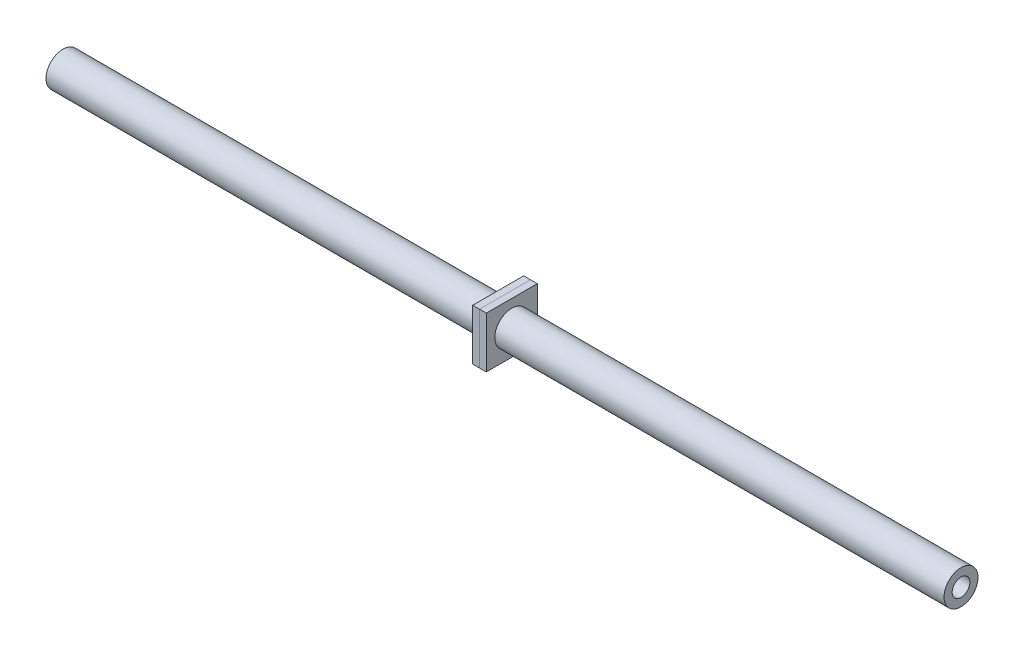
from build123d import *

# Parameters (mm, degrees)
SKETCH11_R            = 6.35
SKETCH11_R_2          = 3.302
PULL_ROD_MEMBER_DEPTH = 335.464234074
PULL_START            = 165.1
SKETCH12_W            = 19.05
SKETCH12_H            = 19.05
SKETCH12_R            = 6.35
PULL_ROD_NUT_1_DEPTH  = 2.54
SKETCH14_W            = 19.05
SKETCH14_H            = 19.05
SKETCH14_R            = 6.35
PULL_ROD_NUT_2_DEPTH  = 2.54


with BuildPart() as part:
    # Sketch11 → Pull Rod Member (new body)
    with BuildSketch(Plane.YZ):
        Circle(SKETCH11_R)
        Circle(SKETCH11_R_2, mode=Mode.SUBTRACT)
    extrude(amount=PULL_ROD_MEMBER_DEPTH)


with BuildPart() as body_2:
    # Sketch12 → Pull Rod Nut 1 (new body)
    with BuildSketch(Plane(origin=(0, 0, 0), x_dir=(0, 0, -1), z_dir=(1, 0, 0)).offset(PULL_START)):
        Rectangle(SKETCH12_W, SKETCH12_H)
        Circle(SKETCH12_R, mode=Mode.SUBTRACT)
    extrude(amount=PULL_ROD_NUT_1_DEPTH)


with BuildPart() as body_3:
    # Sketch14 → Pull Rod Nut 2 (new body)
    with BuildSketch(Plane(origin=(0, 0, 0), x_dir=(0, 0, -1), z_dir=(1, 0, 0)).offset(PULL_START)):
        Rectangle(SKETCH14_W, SKETCH14_H)
        with Locations(Location((0, 0, 0), (0, 0, 180))):
            Circle(SKETCH14_R, mode=Mode.SUBTRACT)
    extrude(amount=-PULL_ROD_NUT_2_DEPTH)


solid = Compound([part.part, body_2.part, body_3.part])
